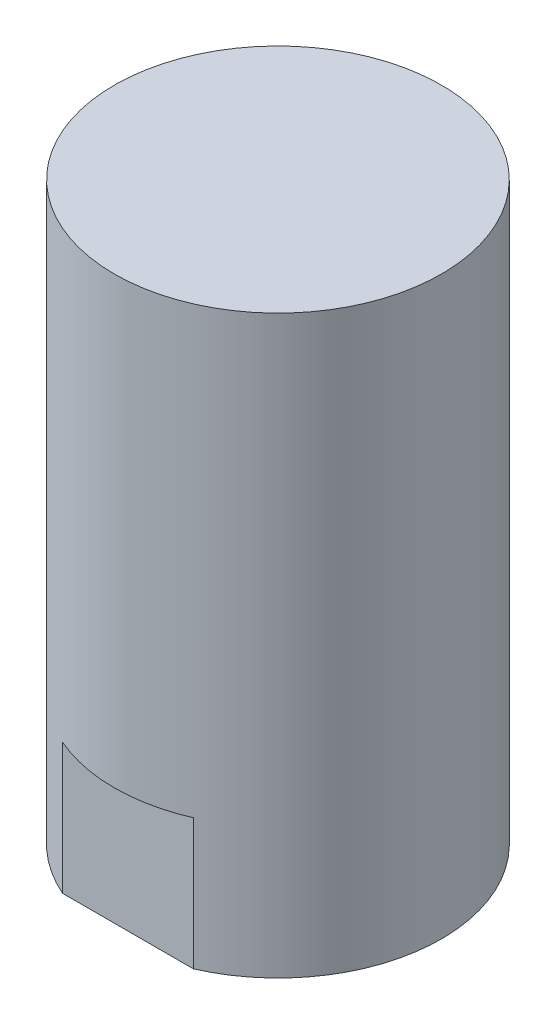
from build123d import *

# Parameters (mm, degrees)
SKETCH1_R           = 12.5
BOSS_EXTRUDE1_DEPTH = 44
SKETCH3_R           = 5
CUT_EXTRUDE1_DEPTH  = 10


with BuildPart() as part:
    # Sketch1 → Boss-Extrude1 (new body)
    with BuildSketch(Plane(origin=(0, 0, 0), x_dir=(1, 0, 0), z_dir=(0, 1, 0))):
        Circle(SKETCH1_R)
    extrude(amount=BOSS_EXTRUDE1_DEPTH)

    # Sketch3 → Cut-Extrude1 (cut)
    with BuildSketch(Plane.XZ):
        Circle(SKETCH3_R)
        with BuildLine():
            Line((-5, 11.456439237), (5, 11.456439237))
            ThreePointArc((5, 11.456439237), (0, 12.5), (-5, 11.456439237))
        make_face()
    extrude(amount=-CUT_EXTRUDE1_DEPTH, mode=Mode.SUBTRACT)


solid = part.part
